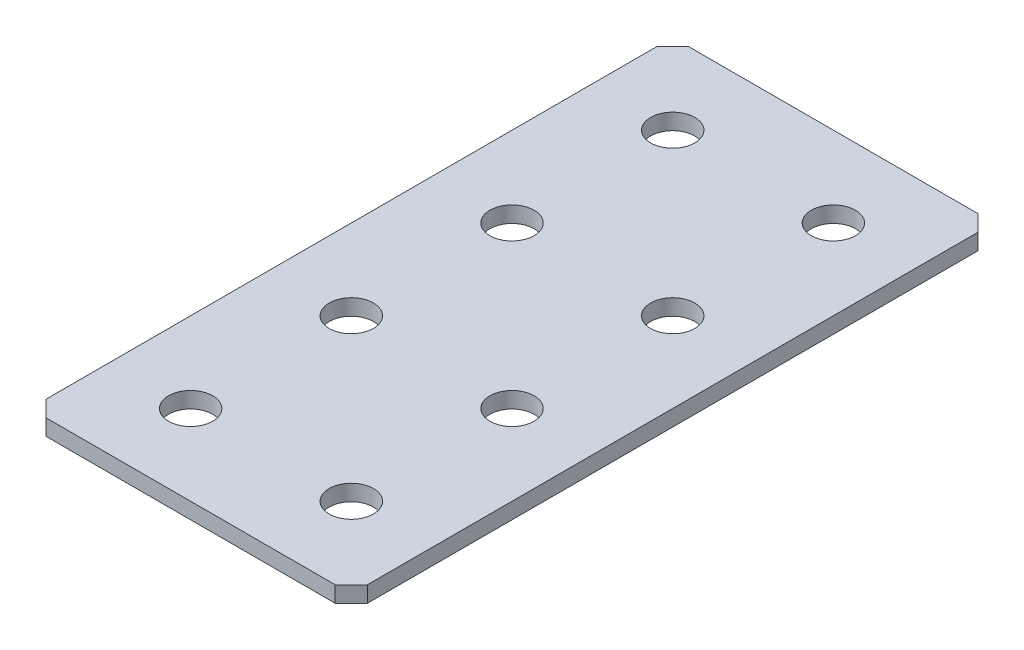
from build123d import *

# Parameters (mm, degrees)
SKETCH_1_W        = 40
SKETCH_1_H        = 80
EXTRUDE_1_DEPTH   = 2
CHAMFER_1_SIZE    = 2
HOLE_WIZARD_M51_D = 5.5


with BuildPart() as part:
    # Эскиз1 → Бобышка-Вытянуть1 (new body)
    with BuildSketch(Plane(origin=(0, 0, 0), x_dir=(1, 0, 0), z_dir=(0, 1, 0))):
        Rectangle(SKETCH_1_W, SKETCH_1_H)
    extrude(amount=EXTRUDE_1_DEPTH)

    # Фаска1
    chamfer_1_edges = [part.edges().sort_by_distance(p)[0] for p in [
        (20, 1, 40),
        (-20, 1, 40),
        (-20, 1, -40),
        (20, 1, -40),
    ]]
    chamfer(chamfer_1_edges, length=CHAMFER_1_SIZE)

    # Отверстие с зазором M51 (through all)
    with Locations(Plane(origin=(0, 2, 0), x_dir=(1, 0, 0), z_dir=(0, 1, 0))):
        with Locations((-10, 10), (10, 10), (-10, -10), (10, -10), (-10, 30), (10, 30), (10, -30), (-10, -30)):
            Hole(HOLE_WIZARD_M51_D / 2)


solid = part.part
